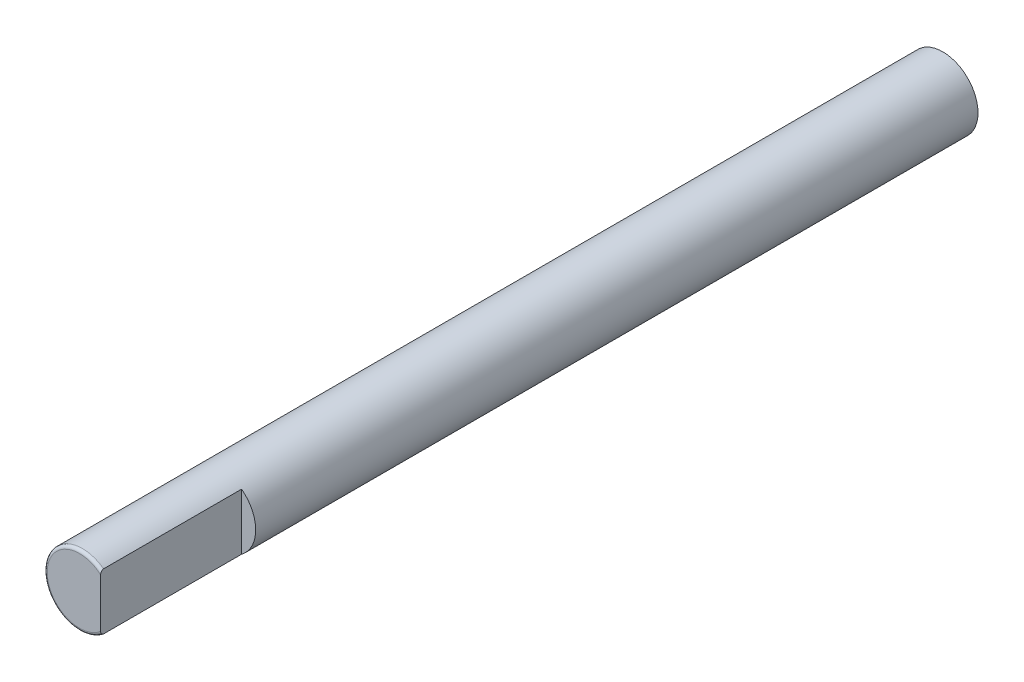
from build123d import *

# Parameters (mm, degrees)
CROQUIS1_R              = 3
SALIENTE_EXTRUIR1_DEPTH = 73.5
REDONDEO1_R             = 0.25
SKETCH1_W               = 3.065124184
SKETCH1_H               = 10
CUT_EXTRUDE1_DEPTH      = 12


with BuildPart() as part:
    # Croquis1 → Saliente-Extruir1 (new body)
    with BuildSketch(Plane.XY):
        Circle(CROQUIS1_R)
    extrude(amount=SALIENTE_EXTRUIR1_DEPTH)

    # Redondeo1
    redondeo1_edges = [part.edges().sort_by_distance(p)[0] for p in [
        (-3, 0, 73.5),
    ]]
    fillet(redondeo1_edges, radius=REDONDEO1_R)

    # Sketch1 → Cut-Extrude1 (cut)
    with BuildSketch(Plane.XY.offset(73.5)):
        with Locations((3.332562092, 1.320530023)):
            Rectangle(SKETCH1_W, SKETCH1_H)
    extrude(amount=-CUT_EXTRUDE1_DEPTH, mode=Mode.SUBTRACT)


solid = part.part
